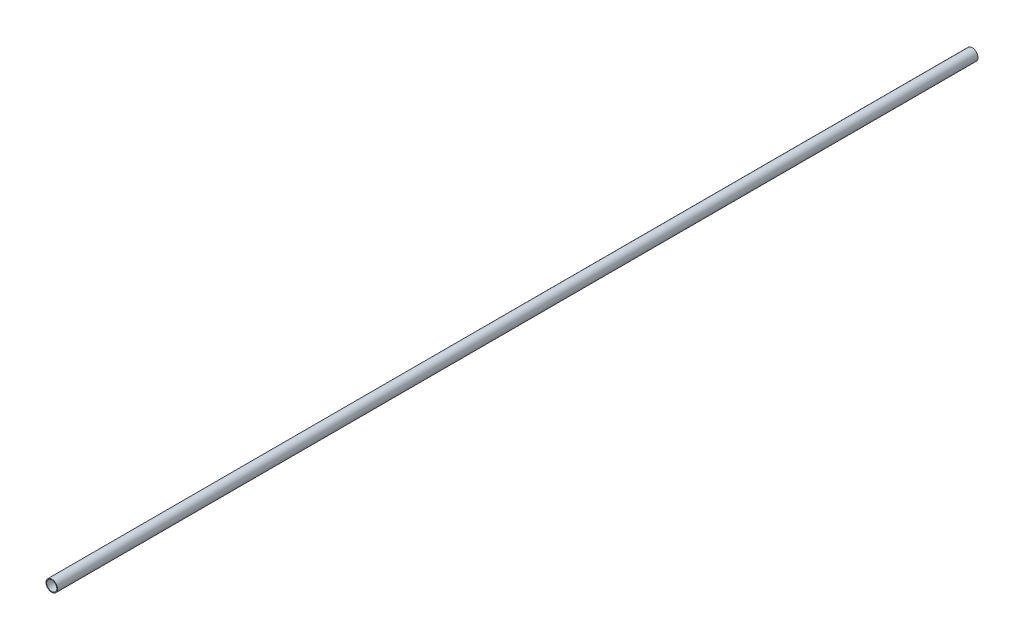
from build123d import *

# Parameters (mm, degrees)
SKETCH1_R           = 12.5
SKETCH1_R_2         = 11
BOSS_EXTRUDE1_DEPTH = 2000


with BuildPart() as part:
    # Sketch1 → Boss-Extrude1 (new body)
    with BuildSketch(Plane.XY):
        Circle(SKETCH1_R)
        Circle(SKETCH1_R_2, mode=Mode.SUBTRACT)
    extrude(amount=BOSS_EXTRUDE1_DEPTH)


solid = part.part
